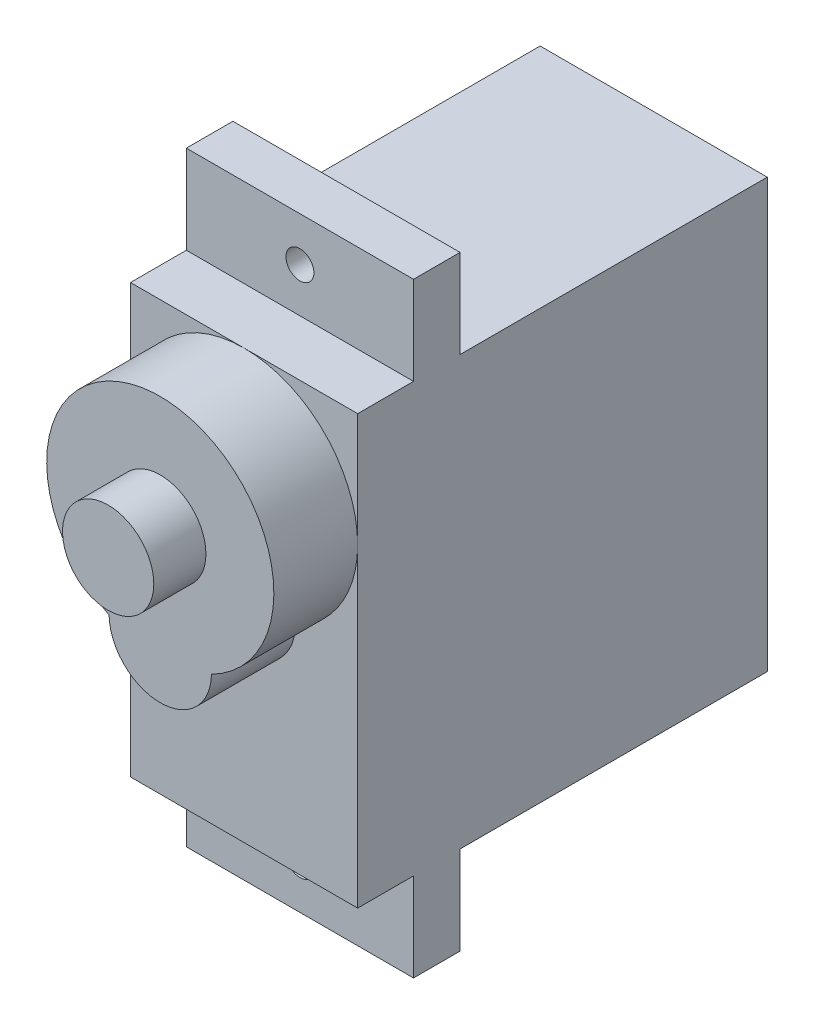
from build123d import *

# Parameters (mm, degrees)
ESQUISSE1_W             = 22
ESQUISSE1_H             = 23
BOSS_EXTRU_1_DEPTH      = 6.1
BOSS_EXTRU_2_DEPTH      = 4.5
ESQUISSE3_R             = 2.45
BOSS_EXTRU_3_DEPTH      = 2.8
ESQUISSE4_W             = 2.5
ESQUISSE4_H             = 4.75
BOSS_EXTRU_4_DEPTH      = 6.1
ENL_V_MAT_EXTRU_1_REACH = 21
ESQUISSE5_R             = 0.75


with BuildPart() as part:
    # Esquisse1 → Boss.-Extru.1 (new body, symmetric)
    with BuildSketch(Plane(origin=(0, 0, 0), x_dir=(0, 0, -1), z_dir=(1, 0, 0))):
        Rectangle(ESQUISSE1_W, ESQUISSE1_H)
    extrude(amount=BOSS_EXTRU_1_DEPTH, both=True)

    # Esquisse2 → Boss.-Extru.2 (add)
    with BuildSketch(Plane.XY.offset(11)):
        with BuildLine():
            ThreePointArc((2.749629517, -0.045138889), (0, 11.5), (-2.749629517, -0.045138889))
            ThreePointArc((-2.749629517, -0.045138889), (0, -2.75), (2.749629517, -0.045138889))
        make_face()
    extrude(amount=BOSS_EXTRU_2_DEPTH)

    # Esquisse3 → Boss.-Extru.3 (add)
    with BuildSketch(Plane.XY.offset(15.5)):
        with Locations((0, 5.4)):
            Circle(ESQUISSE3_R)
    extrude(amount=BOSS_EXTRU_3_DEPTH)

    # Esquisse4 → Boss.-Extru.4 (add, symmetric)
    with BuildSketch(Plane(origin=(0, 0, 0), x_dir=(0, 0, -1), z_dir=(1, 0, 0))):
        with Locations((-6.75, 13.875)):
            Rectangle(ESQUISSE4_W, ESQUISSE4_H)
        with Locations((-6.75, -13.875)):
            Rectangle(ESQUISSE4_W, ESQUISSE4_H)
    extrude(amount=BOSS_EXTRU_4_DEPTH, both=True)

    # Esquisse5 → Enlèv. mat.-Extru.1 (cut, up to next)
    with BuildSketch(Plane.XY.offset(8), mode=Mode.PRIVATE) as enl_v_mat_extru_1_sk1:
        with Locations((0, 13.875)):
            Circle(ESQUISSE5_R)
    enl_v_mat_extru_1_tool1 = extrude(enl_v_mat_extru_1_sk1.sketch, amount=-ENL_V_MAT_EXTRU_1_REACH, mode=Mode.PRIVATE) & part.part
    add(enl_v_mat_extru_1_tool1.solids().sort_by_distance((0, 13.875, 8))[0], mode=Mode.SUBTRACT)
    # Esquisse5 → Enlèv. mat.-Extru.1 (cut, up to next)
    with BuildSketch(Plane.XY.offset(8), mode=Mode.PRIVATE) as enl_v_mat_extru_1_sk2:
        with Locations((0, -13.875)):
            Circle(ESQUISSE5_R)
    enl_v_mat_extru_1_tool2 = extrude(enl_v_mat_extru_1_sk2.sketch, amount=-ENL_V_MAT_EXTRU_1_REACH, mode=Mode.PRIVATE) & part.part
    add(enl_v_mat_extru_1_tool2.solids().sort_by_distance((0, -13.875, 8))[0], mode=Mode.SUBTRACT)


solid = part.part
